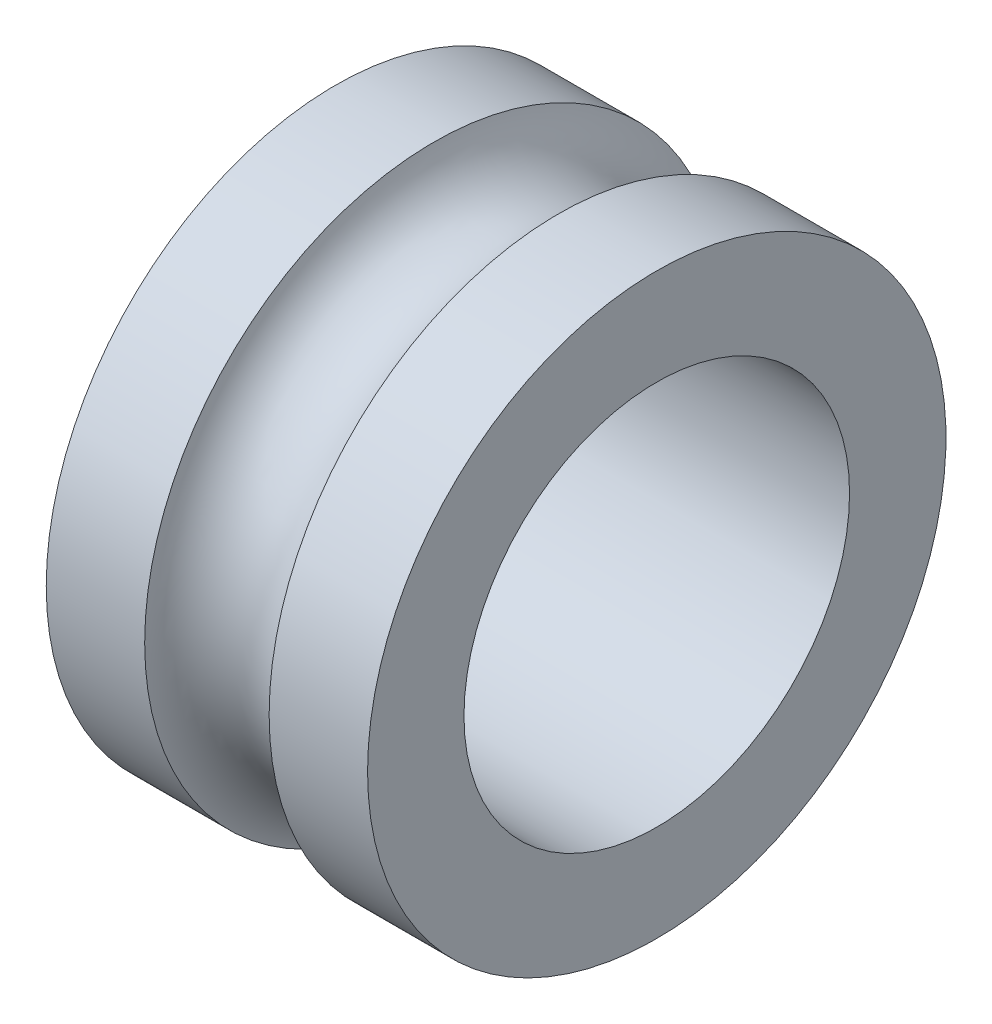
from build123d import *


with BuildPart() as part:
    # Sketch1 → Revolve1 (revolve)
    with BuildSketch(Plane.XY):
        with BuildLine():
            Line((-24.943468517, -4.292635279), (-26.475222681, -4.292635279))
            ThreePointArc((-26.475222681, -4.292635279), (-27.443468517, -5.042635279), (-28.411714354, -4.292635279))
            Line((-28.411714354, -4.292635279), (-29.943468517, -4.292635279))
            Line((-29.943468517, -4.292635279), (-29.943468517, -5.792635279))
            Line((-29.943468517, -5.792635279), (-24.943468517, -5.792635279))
            Line((-24.943468517, -5.792635279), (-24.943468517, -4.292635279))
        make_face()
    revolve(axis=Axis((-27.443468517, -8.792635279, 0), (1, 0, 0)))


solid = part.part
